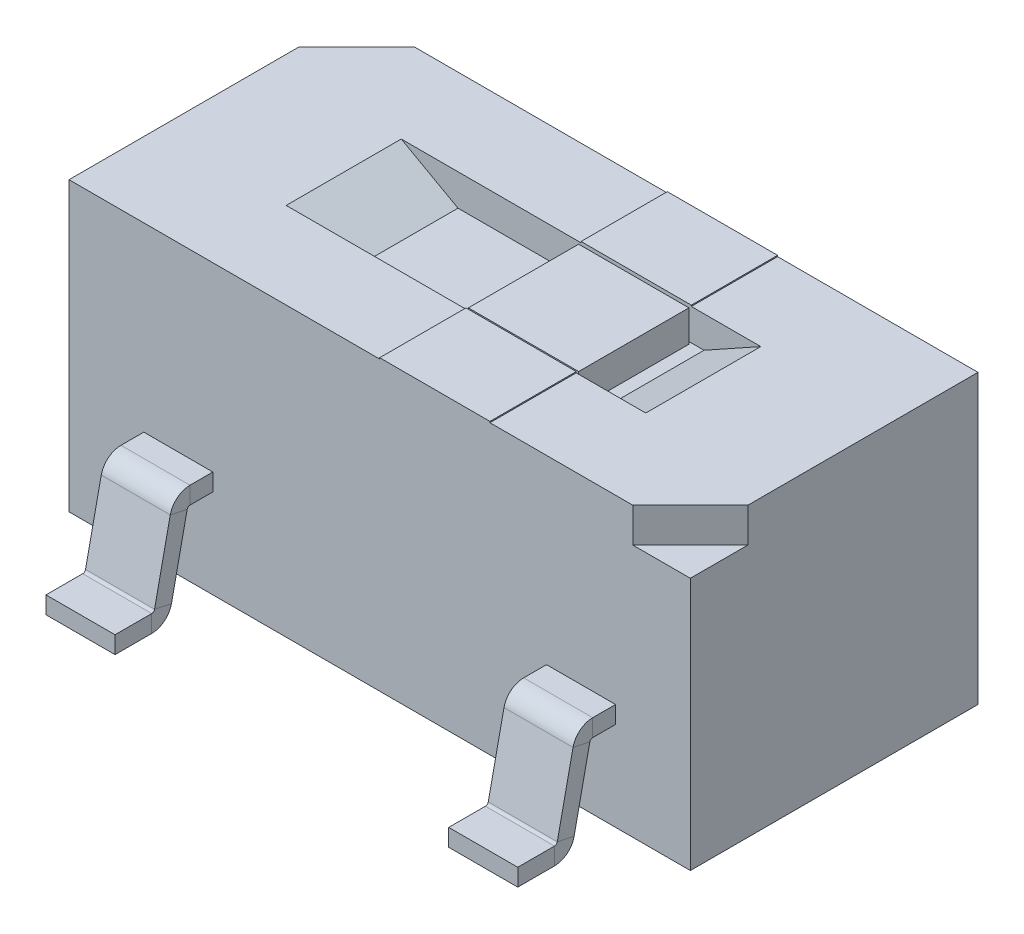
from build123d import *

# Parameters (mm, degrees)
SKETCH1_W               = 5.4
SKETCH1_H               = 2.5
BOSS_EXTRUDE1_DEPTH     = 2.5
CUT_EXTRUDE1_DEPTH      = 0.3
CUT_EXTRUDE2_DEPTH      = 0.5
CUT_EXTRUDE2_DEPTH_BACK = 0.5
SKETCH4_W               = 0.958388154
SKETCH4_H               = 0.958388154
BOSS_EXTRUDE2_DEPTH     = 0.274135
SKETCH5_W               = 0.958388154
SKETCH5_H               = 0.75
BOSS_EXTRUDE3_DEPTH     = 0.01
SKETCH6_W               = 0.6
SKETCH6_H               = 0.15
LPATTERN1_COUNT         = 2
LPATTERN1_PITCH         = 1.75
LPATTERN1_COL_COUNT     = 2
LPATTERN1_COL_PITCH     = 1.75
SKETCH7_W               = 0.897503452
SKETCH7_H               = 1.940022621
CUT_EXTRUDE3_DEPTH      = 0.85


with BuildPart() as part:
    # Sketch1 → Boss-Extrude1 (new body)
    with BuildSketch(Plane(origin=(0, 0, 0), x_dir=(1, 0, 0), z_dir=(0, 1, 0))):
        Rectangle(SKETCH1_W, SKETCH1_H)
    extrude(amount=BOSS_EXTRUDE1_DEPTH)

    # Sketch2 → Cut-Extrude1 (cut)
    with BuildSketch(Plane(origin=(0, 2.5, 0), x_dir=(1, 0, 0), z_dir=(0, 1, 0))):
        Polygon((-2.7, 1.25), (-2.7, 0.75), (-2.2, 1.25), align=None)
        Polygon((2.2, -1.25), (2.7, -1.25), (2.7, -0.75), align=None)
    extrude(amount=-CUT_EXTRUDE1_DEPTH, mode=Mode.SUBTRACT)

    # Sketch3 → Cut-Extrude2 (cut, two sides)
    with BuildSketch(Plane.XY) as cut_extrude2_sk:
        Polygon((1.562546912, 2.5), (1.069337519, 2.22586461), (-1.069337519, 2.22586461), (-1.562546912, 2.5), align=None)
    extrude(amount=CUT_EXTRUDE2_DEPTH, mode=Mode.SUBTRACT)
    extrude(cut_extrude2_sk.sketch, amount=-CUT_EXTRUDE2_DEPTH_BACK, mode=Mode.SUBTRACT)

    # Sketch4 → Boss-Extrude2 (add)
    with BuildSketch(Plane(origin=(0, 2.22586461, 0), x_dir=(1, 0, 0), z_dir=(0, 1, 0))):
        with Locations((0.479194077, 0)):
            Rectangle(SKETCH4_W, SKETCH4_H)
    extrude(amount=BOSS_EXTRUDE2_DEPTH)

    # Sketch5 → Boss-Extrude3 (add)
    with BuildSketch(Plane(origin=(0, 2.5, 0), x_dir=(1, 0, 0), z_dir=(0, 1, 0))):
        with Locations((0.479194077, 0.875)):
            Rectangle(SKETCH5_W, SKETCH5_H)
        with Locations((0.479194077, -0.875)):
            Rectangle(SKETCH5_W, SKETCH5_H)
    extrude(amount=BOSS_EXTRUDE3_DEPTH)

    # Sweep1: sweep along a curve in space
    with BuildLine() as sweep1_path:
        Line((0, 0.85, 1.25), (0, 0.85, 1.44856475))
        ThreePointArc((0, 0.85, 1.44856475), (0, 0.827731782, 1.51147556), (0, 0.770844599, 1.546368138))
        Line((0, 0.770844599, 1.546368138), (0, 0.129155401, 1.683129801))
        ThreePointArc((0, 0.129155401, 1.683129801), (0, 0.072268218, 1.718022379), (0, 0.05, 1.780933189))
        Line((0, 0.05, 1.780933189), (0, 0.05, 2.1))
    # Sketch6 → Sweep1 (sweep)
    with BuildSketch(Plane.XY.offset(1.25)):
        with Locations((0, 0.85)):
            Rectangle(SKETCH6_W, SKETCH6_H)
    sweep1 = sweep(path=sweep1_path.line)

    # Mirror1: Sweep1 across plane
    add(sweep1.mirror(Plane.XY))

    # LPattern1: Sweep1 ×2
    with Locations(*[(i * LPATTERN1_PITCH, 0, 0) for i in range(1, LPATTERN1_COUNT)]):
        add(sweep1)

    # LPattern1 col: Sweep1 ×2
    with Locations(*[(-i * LPATTERN1_COL_PITCH, 0, 0) for i in range(1, LPATTERN1_COL_COUNT)]):
        add(sweep1)

    # Sketch7 → Cut-Extrude3 (cut)
    with BuildSketch(Plane.XY.offset(2.1)):
        with Locations((0, 0.786478049)):
            Rectangle(SKETCH7_W, SKETCH7_H)
    extrude(amount=-CUT_EXTRUDE3_DEPTH, mode=Mode.SUBTRACT)


solid = part.part
